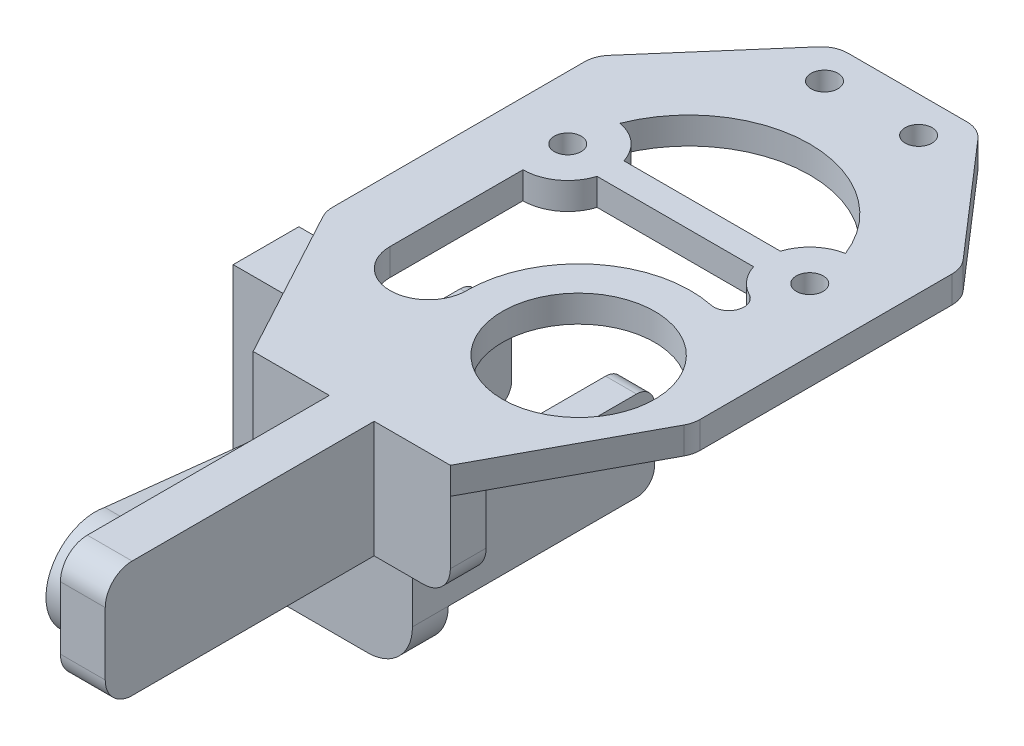
from build123d import *

# Parameters (mm, degrees)
SKETCH1_R            = 1.5
SKETCH1_R_2          = 8.5
BOSS_EXTRUDE1_DEPTH  = 1.5
FILLET1_R            = 3
BOSS_EXTRUDE2_DEPTH  = 30
SKETCH7_W            = 3.75
SKETCH7_H            = 23.325864092
BOSS_EXTRUDE4_DEPTH  = 25
SKETCH10_W           = 3.45
SKETCH10_H           = 25
BOSS_EXTRUDE15_DEPTH = 23
SKETCH11_W           = 3.75
SKETCH11_H           = 15
CUT_EXTRUDE1_DEPTH   = 20
SKETCH12_W           = 3.45
SKETCH12_H           = 15
CUT_EXTRUDE2_DEPTH   = 20
SKETCH13_W           = 22
SKETCH13_H           = 4
BOSS_EXTRUDE16_DEPTH = 10
SKETCH14_W           = 2.5
SKETCH14_H           = 13
BOSS_EXTRUDE17_DEPTH = 30
FILLET3_R            = 3
FILLET4_R            = 3
FILLET5_R            = 3
FILLET6_R            = 3
FILLET7_R            = 2
FILLET8_R            = 2
FILLET9_R            = 2
FILLET10_R           = 2
FILLET11_R           = 5
FILLET12_R           = 5
BOSS_EXTRUDE18_DEPTH = 3


with BuildPart() as part:
    # Sketch1 → Boss-Extrude1 (new body, symmetric)
    with BuildSketch(Plane(origin=(0, 0, 0), x_dir=(1, 0, 0), z_dir=(0, 1, 0))):
        Polygon((8, 24.400284093), (-8, 24.400284093), (-20.5, 10), (-20.5, -20), (-11, -37.599715907), (11, -37.599715907), (20.5, -20), (20.5, 10), align=None)
        with Locations((-5.25, 20.39454584)):
            Circle(SKETCH1_R, mode=Mode.SUBTRACT)
        with Locations((5.25, 20.39454584)):
            Circle(SKETCH1_R, mode=Mode.SUBTRACT)
        with Locations((-13.5, 0)):
            Circle(SKETCH1_R, mode=Mode.SUBTRACT)
        with Locations((13.5, 0)):
            Circle(SKETCH1_R, mode=Mode.SUBTRACT)
        with Locations((7.530163354, -19.817414772)):
            Circle(SKETCH1_R_2, mode=Mode.SUBTRACT)
        with BuildLine():
            Line((-13.5, -5), (-13.5, -19.817414772))
            ThreePointArc((-13.5, -19.817414772), (-9.234918323, -24.082496449), (-4.969836646, -19.817414772))
            ThreePointArc((-4.969836646, -19.817414772), (-0.361028795, -10.12313365), (10.06681719, -7.57750516))
            ThreePointArc((10.06681719, -7.57750516), (11.99598649, -6.493442694), (11.187975781, -4.433344563))
            ThreePointArc((11.187975781, -4.433344563), (9.667400631, -3.211102938), (8.730303993, -1.5))
            Line((8.730303993, -1.5), (-8.730303993, -1.5))
            ThreePointArc((-8.730303993, -1.5), (-10.541960108, -4.031128874), (-13.5, -5))
        make_face(mode=Mode.SUBTRACT)
        with BuildLine():
            Line((8.730303993, 1.5), (-8.730303993, 1.5))
            ThreePointArc((-8.730303993, 1.5), (-10.179901517, 3.738575405), (-12.574074074, 4.913518208))
            ThreePointArc((-12.574074074, 4.913518208), (0, 13.5), (12.574074074, 4.913518208))
            ThreePointArc((12.574074074, 4.913518208), (10.179901517, 3.738575405), (8.730303993, 1.5))
        make_face(mode=Mode.SUBTRACT)
    extrude(amount=BOSS_EXTRUDE1_DEPTH, both=True)

    # Fillet1
    fillet1_edges = [part.edges().sort_by_distance(p)[0] for p in [
        (-20.5, 0, 20),
        (-20.5, 0, -10),
        (-8, 0, -24.400284093),
        (8, 0, -24.400284093),
        (20.5, 0, -10),
        (20.5, 0, 20),
    ]]
    fillet(fillet1_edges, radius=FILLET1_R)

    # Sketch4 → Boss-Extrude2 (add)
    with BuildSketch(Plane.XZ.offset(1.5)):
        Polygon((-23.5, 27.325864092), (-23.5, 23.325864092), (-18.70476029, 23.325864092), (-16.545634529, 27.325864092), align=None)
        with BuildLine():
            Line((-18.70476029, 23.325864092), (-13.5, 23.325864092))
            Line((-13.5, 23.325864092), (-11.660141009, 23.325864092))
            ThreePointArc((-11.660141009, 23.325864092), (-9.234918323, 24.082496449), (-6.809695637, 23.325864092))
            Line((-6.809695637, 23.325864092), (-3.5, 23.325864092))
            Line((-3.5, 23.325864092), (-3.5, 27.325864092))
            Line((-3.5, 27.325864092), (-16.545634529, 27.325864092))
            Line((-16.545634529, 27.325864092), (-18.70476029, 23.325864092))
        make_face()
    extrude(amount=BOSS_EXTRUDE2_DEPTH)

    # Sketch7 → Boss-Extrude4 (add)
    with BuildSketch(Plane.XZ.offset(1.5)):
        with Locations((-21.625, 11.662932046)):
            Rectangle(SKETCH7_W, SKETCH7_H)
    extrude(amount=BOSS_EXTRUDE4_DEPTH)

    # Sketch10 → Boss-Extrude15 (add)
    with BuildSketch(Plane(origin=(0, 0, 23.325864092), x_dir=(-1, 0, 0), z_dir=(0, 0, -1))):
        with Locations((5.225, -14)):
            Rectangle(SKETCH10_W, SKETCH10_H)
    extrude(amount=BOSS_EXTRUDE15_DEPTH)

    # Sketch11 → Cut-Extrude1 (cut)
    with BuildSketch(Plane(origin=(0, 0, 0), x_dir=(-1, 0, 0), z_dir=(0, 0, -1))):
        with Locations((21.625, -9)):
            Rectangle(SKETCH11_W, SKETCH11_H)
    extrude(amount=-CUT_EXTRUDE1_DEPTH, mode=Mode.SUBTRACT)

    # Sketch12 → Cut-Extrude2 (cut)
    with BuildSketch(Plane(origin=(0, 0, 0.325864092), x_dir=(-1, 0, 0), z_dir=(0, 0, -1))):
        with Locations((5.225, -9)):
            Rectangle(SKETCH12_W, SKETCH12_H)
    extrude(amount=-CUT_EXTRUDE2_DEPTH, mode=Mode.SUBTRACT)

    # Sketch13 → Boss-Extrude16 (add)
    with BuildSketch(Plane.XZ.offset(1.5)):
        with Locations((0, 35.599715907)):
            Rectangle(SKETCH13_W, SKETCH13_H)
    extrude(amount=BOSS_EXTRUDE16_DEPTH)

    # Sketch14 → Boss-Extrude17 (add)
    with BuildSketch(Plane.XY.offset(37.599715907)):
        with Locations((1.25, -5)):
            Rectangle(SKETCH14_W, SKETCH14_H)
        with Locations((-1.25, -5)):
            Rectangle(SKETCH14_W, SKETCH14_H)
    extrude(amount=BOSS_EXTRUDE17_DEPTH)

    # Fillet3
    fillet3_edges = [part.edges().sort_by_distance(p)[0] for p in [
        (-11, -11.5, 35.599715907),
    ]]
    fillet(fillet3_edges, radius=FILLET3_R)

    # Fillet4
    fillet4_edges = [part.edges().sort_by_distance(p)[0] for p in [
        (11, -11.5, 35.599715907),
    ]]
    fillet(fillet4_edges, radius=FILLET4_R)

    # Fillet5
    fillet5_edges = [part.edges().sort_by_distance(p)[0] for p in [
        (0, 1.5, 67.599715907),
    ]]
    fillet(fillet5_edges, radius=FILLET5_R)

    # Fillet6
    fillet6_edges = [part.edges().sort_by_distance(p)[0] for p in [
        (0, -11.5, 67.599715907),
    ]]
    fillet(fillet6_edges, radius=FILLET6_R)

    # Fillet7
    fillet7_edges = [part.edges().sort_by_distance(p)[0] for p in [
        (-21.625, -16.5, 0),
    ]]
    fillet(fillet7_edges, radius=FILLET7_R)

    # Fillet8
    fillet8_edges = [part.edges().sort_by_distance(p)[0] for p in [
        (-21.625, -26.5, 0),
    ]]
    fillet(fillet8_edges, radius=FILLET8_R)

    # Fillet9
    fillet9_edges = [part.edges().sort_by_distance(p)[0] for p in [
        (-5.225, -26.5, 0.325864092),
    ]]
    fillet(fillet9_edges, radius=FILLET9_R)

    # Fillet10
    fillet10_edges = [part.edges().sort_by_distance(p)[0] for p in [
        (-5.225, -16.5, 0.325864092),
    ]]
    fillet(fillet10_edges, radius=FILLET10_R)

    # Fillet11
    fillet11_edges = [part.edges().sort_by_distance(p)[0] for p in [
        (-3.5, -31.5, 25.325864092),
    ]]
    fillet(fillet11_edges, radius=FILLET11_R)

    # Fillet12
    fillet12_edges = [part.edges().sort_by_distance(p)[0] for p in [
        (-23.5, -31.5, 25.325864092),
    ]]
    fillet(fillet12_edges, radius=FILLET12_R)

    # Sketch15 → Boss-Extrude18 (add)
    with BuildSketch(Plane.ZY.offset(2.5)):
        with BuildLine():
            Line((60.019494917, -10.664595798), (44.083601773, -9.563551575))
            ThreePointArc((44.083601773, -9.563551575), (40.114289707, -5.53663584), (44.039052889, -1.466289101))
            Line((44.039052889, -1.466289101), (59.646971548, 0.211283454))
            ThreePointArc((59.646971548, 0.211283454), (66.207952811, -5.008307663), (60.019494917, -10.664595798))
        make_face()
        with BuildLine():
            Line((60.218460063, -8.673574683), (44.164228414, -7.564354205))
            ThreePointArc((44.164228414, -7.564354205), (42.114228414, -5.514354205), (44.164228414, -3.464354205))
            Line((44.164228414, -3.464354205), (59.955274566, -1.767098714))
            ThreePointArc((59.955274566, -1.767098714), (64.208636435, -5.063268193), (60.218460063, -8.673574683))
        make_face(mode=Mode.SUBTRACT)
    extrude(amount=BOSS_EXTRUDE18_DEPTH)


solid = part.part
